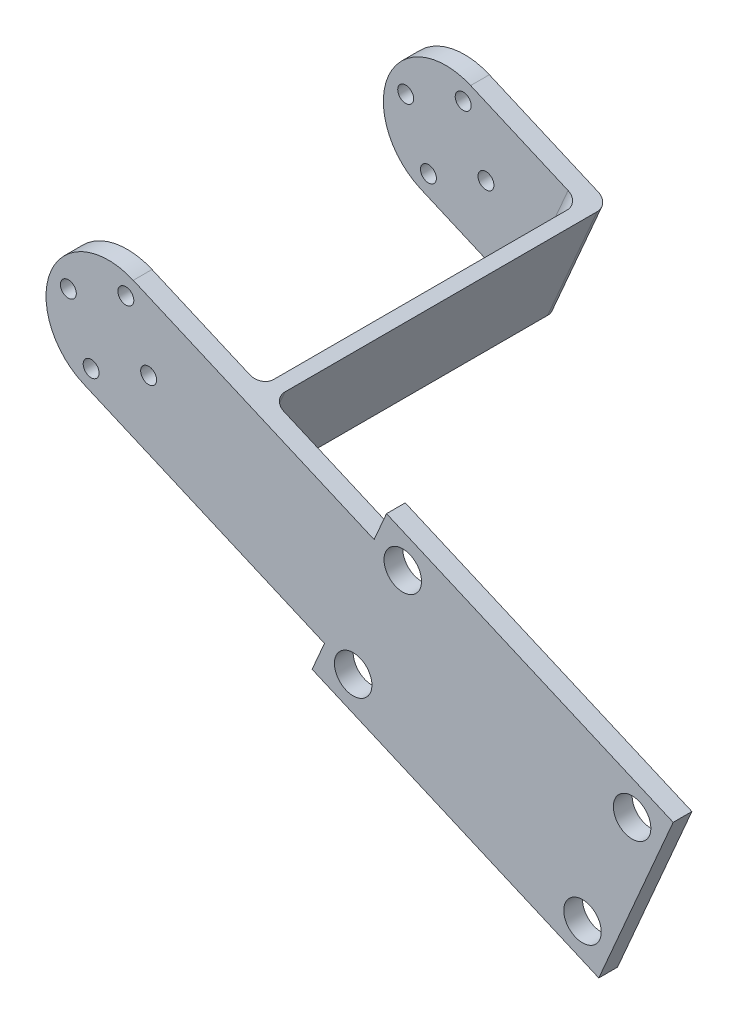
from build123d import *

# Parameters (mm, degrees)
ESQUISSE2_R        = 1.275
ESQUISSE2_R_2      = 3
BOSS_EXTRU_1_DEPTH = 3
BOSS_EXTRU_4_DEPTH = 51
CONG_1_R           = 2
ESQUISSE6_R        = 1.275
BOSS_EXTRU_5_DEPTH = 3
CONG_2_R           = 2


with BuildPart() as part:
    # Esquisse2 → Boss.-Extru.1 (new body)
    with BuildSketch(Plane.XY.offset(-10.755524)):
        with BuildLine():
            Line((42.518708, -7.493961), (3.9696, 9.178359))
            ThreePointArc((3.9696, 9.178359), (-9.178359, 3.9696), (-3.9696, -9.178359))
            Line((-3.9696, -9.178359), (34.579508, -25.850679))
            Line((34.579508, -25.850679), (32.594708, -30.439859))
            Line((32.594708, -30.439859), (78.486504, -50.287859))
            Line((78.486504, -50.287859), (90.395304, -22.752781))
            Line((90.395304, -22.752781), (44.503508, -2.904781))
            Line((44.503508, -2.904781), (42.518708, -7.493961))
        make_face()
        with Locations((6.424851, -2.77872)):
            Circle(ESQUISSE2_R, mode=Mode.SUBTRACT)
        with Locations((-2.77872, -6.424851)):
            Circle(ESQUISSE2_R, mode=Mode.SUBTRACT)
        with Locations((-6.424851, 2.77872)):
            Circle(ESQUISSE2_R, mode=Mode.SUBTRACT)
        with Locations((2.77872, 6.424851)):
            Circle(ESQUISSE2_R, mode=Mode.SUBTRACT)
        with Locations((75.882124, -43.713879)):
            Circle(ESQUISSE2_R_2, mode=Mode.SUBTRACT)
        with Locations((83.821324, -25.357161)):
            Circle(ESQUISSE2_R_2, mode=Mode.SUBTRACT)
        with Locations((47.107888, -9.478761)):
            Circle(ESQUISSE2_R_2, mode=Mode.SUBTRACT)
        with Locations((39.168688, -27.835479)):
            Circle(ESQUISSE2_R_2, mode=Mode.SUBTRACT)
    extrude(amount=BOSS_EXTRU_1_DEPTH)

    # Esquisse5 → Boss.-Extru.4 (add)
    with BuildSketch(Plane(origin=(0, 0, -10.755524), x_dir=(-1, 0, 0), z_dir=(0, 0, -1))):
        Polygon((-13.469282, -16.720599), (-21.408482, 1.636119), (-23.244154, 0.842199), (-15.304954, -17.514519), align=None)
    extrude(amount=BOSS_EXTRU_4_DEPTH)

    # Congé1
    cong_1_edges = [part.edges().sort_by_distance(p)[0] for p in [
        (19.274554, -8.33616, -10.755524),
        (17.438882, -7.54224, -10.755524),
    ]]
    fillet(cong_1_edges, radius=CONG_1_R)

    # Esquisse6 → Boss.-Extru.5 (add)
    with BuildSketch(Plane(origin=(0, 0, -61.755524), x_dir=(-1, 0, 0), z_dir=(0, 0, -1))):
        with BuildLine():
            Line((3.9696, -9.178359), (-11.63361, -15.926679))
            Line((-11.63361, -15.926679), (-15.304954, -17.514519))
            Line((-15.304954, -17.514519), (-23.244154, 0.842199))
            Line((-23.244154, 0.842199), (-19.57281, 2.430039))
            Line((-19.57281, 2.430039), (-3.9696, 9.178359))
            ThreePointArc((-3.9696, 9.178359), (9.178359, 3.9696), (3.9696, -9.178359))
        make_face()
        with Locations((6.424851, 2.77872)):
            Circle(ESQUISSE6_R, mode=Mode.SUBTRACT)
        with Locations((-2.77872, 6.424851)):
            Circle(ESQUISSE6_R, mode=Mode.SUBTRACT)
        with Locations((-6.424851, -2.77872)):
            Circle(ESQUISSE6_R, mode=Mode.SUBTRACT)
        with Locations((2.77872, -6.424851)):
            Circle(ESQUISSE6_R, mode=Mode.SUBTRACT)
    extrude(amount=BOSS_EXTRU_5_DEPTH)

    # Congé2
    cong_2_edges = [part.edges().sort_by_distance(p)[0] for p in [
        (17.438882, -7.54224, -61.755524),
        (19.274554, -8.33616, -64.755524),
    ]]
    fillet(cong_2_edges, radius=CONG_2_R)


solid = part.part
